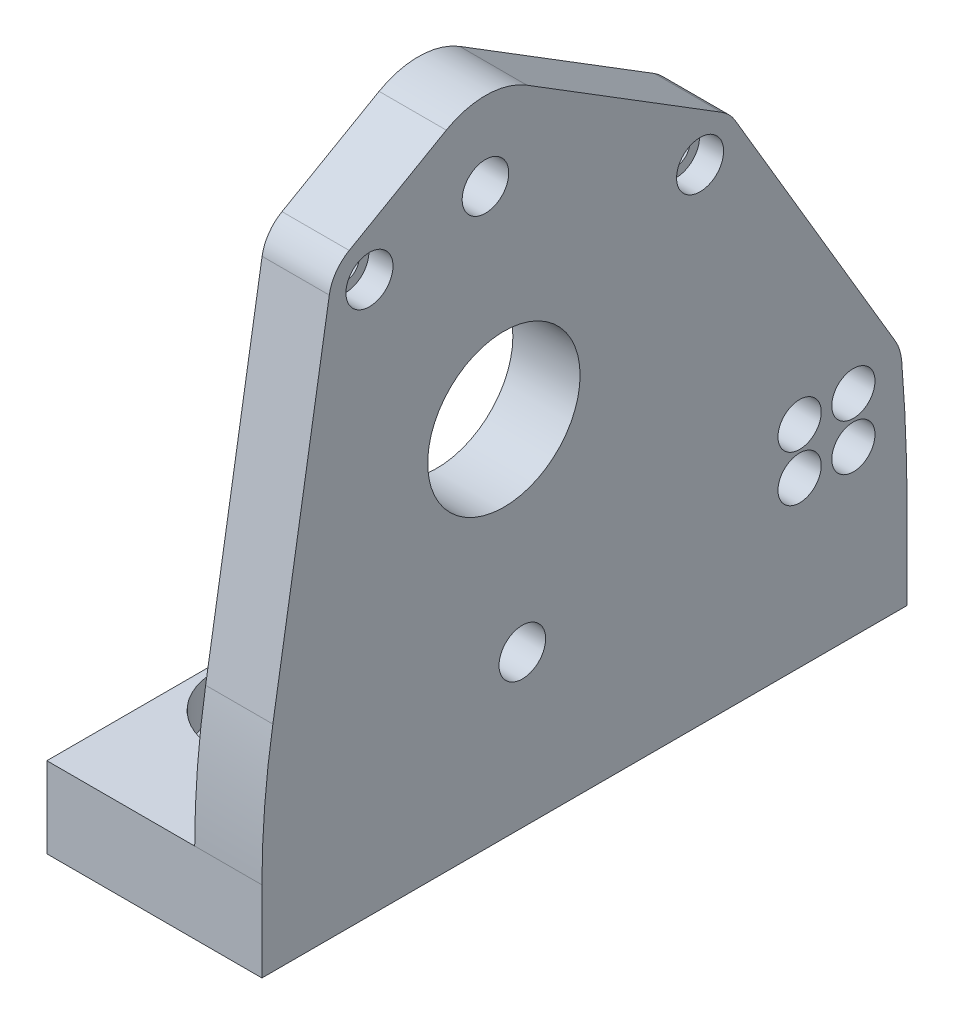
from build123d import *

# Parameters (mm, degrees)
BOSS_EXTRUDE1_DEPTH                            = 76.2
F_18_0MM_DIAMETER_HOLE1_D                      = 18
CBORE_FOR_M5_HEX_HEAD_BOLT1_D                  = 5.5
CBORE_FOR_M5_HEX_HEAD_BOLT1_DEPTH              = 45.974
CBORE_FOR_M5_HEX_HEAD_BOLT1_CBORE_D            = 12.24
CBORE_FOR_M5_HEX_HEAD_BOLT1_CBORE_DEPTH        = 3.58
CBORE_FOR_M5_HEX_HEAD_BOLT1_TIP                = 1.652366702
CBORE_FOR_4_SOCKET_HEAD_CAP_SCREW1_D           = 3.2639
CBORE_FOR_4_SOCKET_HEAD_CAP_SCREW1_DEPTH       = 45.974
CBORE_FOR_4_SOCKET_HEAD_CAP_SCREW1_CBORE_D     = 5.55752
CBORE_FOR_4_SOCKET_HEAD_CAP_SCREW1_CBORE_DEPTH = 2.8448
CBORE_FOR_4_SOCKET_HEAD_CAP_SCREW1_TIP         = 0.980574487
F_10_CLEARANCE_HOLE1_D                         = 5.1054
CUT_EXTRUDE2_DEPTH                             = 26.4
CUT_EXTRUDE2_DEPTH_BACK                        = 1
CBORE_FOR_1_4_HEX_MACHINE_SCREW1_D             = 6.7564
CBORE_FOR_1_4_HEX_MACHINE_SCREW1_CBORE_D       = 15.875
CBORE_FOR_1_4_HEX_MACHINE_SCREW1_CBORE_DEPTH   = 4.826


with BuildPart() as part:
    # Sketch1 → Boss-Extrude1 (new body)
    with BuildSketch(Plane.XY):
        Polygon((0, 0), (0, 9.525), (17.4625, 9.525), (17.4625, 79.375), (25.4, 79.375), (25.4, 0), align=None)
    extrude(amount=BOSS_EXTRUDE1_DEPTH)

    # Ø18.0mm Diameter Hole1 (through all)
    with Locations(Plane(origin=(25.4, 0, 0), x_dir=(0, 0, -1), z_dir=(1, 0, 0))):
        with Locations((-47.625, 42.8625)):
            Hole(F_18_0MM_DIAMETER_HOLE1_D / 2)

    # CBORE for M5 Hex Head Bolt1
    with Locations(Plane.ZY.offset(-17.4625)):
        with Locations((49.803893572, 67.76736749), (45.446106428, 17.95763251)):
            CounterBoreHole(CBORE_FOR_M5_HEX_HEAD_BOLT1_D / 2, CBORE_FOR_M5_HEX_HEAD_BOLT1_CBORE_D / 2, CBORE_FOR_M5_HEX_HEAD_BOLT1_CBORE_DEPTH, depth=CBORE_FOR_M5_HEX_HEAD_BOLT1_DEPTH)
            with Locations((0, 0, -(CBORE_FOR_M5_HEX_HEAD_BOLT1_DEPTH + CBORE_FOR_M5_HEX_HEAD_BOLT1_TIP / 2))):  # 118° drill point
                Cone(0, CBORE_FOR_M5_HEX_HEAD_BOLT1_D / 2, CBORE_FOR_M5_HEX_HEAD_BOLT1_TIP, mode=Mode.SUBTRACT)

    # CBORE for #4 Socket Head Cap Screw1
    with Locations(Plane(origin=(25.4, 0, 0), x_dir=(0, 0, -1), z_dir=(1, 0, 0))):
        with Locations((-24.453273137, 57.320623121), (-63.5, 65.0875)):
            CounterBoreHole(CBORE_FOR_4_SOCKET_HEAD_CAP_SCREW1_D / 2, CBORE_FOR_4_SOCKET_HEAD_CAP_SCREW1_CBORE_D / 2, CBORE_FOR_4_SOCKET_HEAD_CAP_SCREW1_CBORE_DEPTH, depth=CBORE_FOR_4_SOCKET_HEAD_CAP_SCREW1_DEPTH)
            with Locations((0, 0, -(CBORE_FOR_4_SOCKET_HEAD_CAP_SCREW1_DEPTH + CBORE_FOR_4_SOCKET_HEAD_CAP_SCREW1_TIP / 2))):  # 118° drill point
                Cone(0, CBORE_FOR_4_SOCKET_HEAD_CAP_SCREW1_D / 2, CBORE_FOR_4_SOCKET_HEAD_CAP_SCREW1_TIP, mode=Mode.SUBTRACT)

    # #10 Clearance Hole1 (through all)
    with Locations(Plane.ZY.offset(-17.4625)):
        with Locations((6.35, 24.863549414), (12.7, 24.863549414), (6.35, 19.395959874), (12.7, 19.395959874)):
            Hole(F_10_CLEARANCE_HOLE1_D / 2)

    # Sketch10 → Cut-Extrude2 (cut, two sides)
    with BuildSketch(Plane(origin=(0, 0, 0), x_dir=(0, 0, -1), z_dir=(1, 0, 0))) as cut_extrude2_sk:
        with BuildLine():
            ThreePointArc((-74.909422182, 25.327542498), (-75.876819337, 17.452577507), (-76.2, 9.525))
            Line((-76.2, 9.525), (-76.2, 79.375))
            Line((-76.2, 79.375), (0, 79.375))
            Line((0, 79.375), (0, 9.525))
            ThreePointArc((0, 9.525), (-0.160347065, 17.432771339), (-0.641124655, 25.327542498))
            ThreePointArc((-0.641124655, 25.327542498), (-0.890670545, 26.596255157), (-1.418437728, 27.776664731))
            Line((-1.418437728, 27.776664731), (-20.314478636, 59.765443848))
            ThreePointArc((-20.314478636, 59.765443848), (-21.017481453, 60.682483292), (-21.919014013, 61.405264965))
            Line((-21.919014013, 61.405264965), (-44.903501732, 75.665670144))
            ThreePointArc((-44.903501732, 75.665670144), (-49.642737782, 77.060970334), (-54.427500457, 75.830821116))
            Line((-54.427500457, 75.830821116), (-65.891118571, 69.257550393))
            ThreePointArc((-65.891118571, 69.257550393), (-67.449429859, 67.827713877), (-68.243251822, 65.867455417))
            Line((-68.243251822, 65.867455417), (-74.909422182, 25.327542498))
        make_face()
    extrude(amount=CUT_EXTRUDE2_DEPTH, mode=Mode.SUBTRACT)
    extrude(cut_extrude2_sk.sketch, amount=-CUT_EXTRUDE2_DEPTH_BACK, mode=Mode.SUBTRACT)

    # CBORE for 1/4 Hex Machine Screw1 (through all)
    with Locations(Plane(origin=(0, 9.525, 0), x_dir=(1, 0, 0), z_dir=(0, 1, 0))):
        with Locations((8.73125, -19.05), (8.73125, -57.15)):
            CounterBoreHole(CBORE_FOR_1_4_HEX_MACHINE_SCREW1_D / 2, CBORE_FOR_1_4_HEX_MACHINE_SCREW1_CBORE_D / 2, CBORE_FOR_1_4_HEX_MACHINE_SCREW1_CBORE_DEPTH)


solid = part.part
